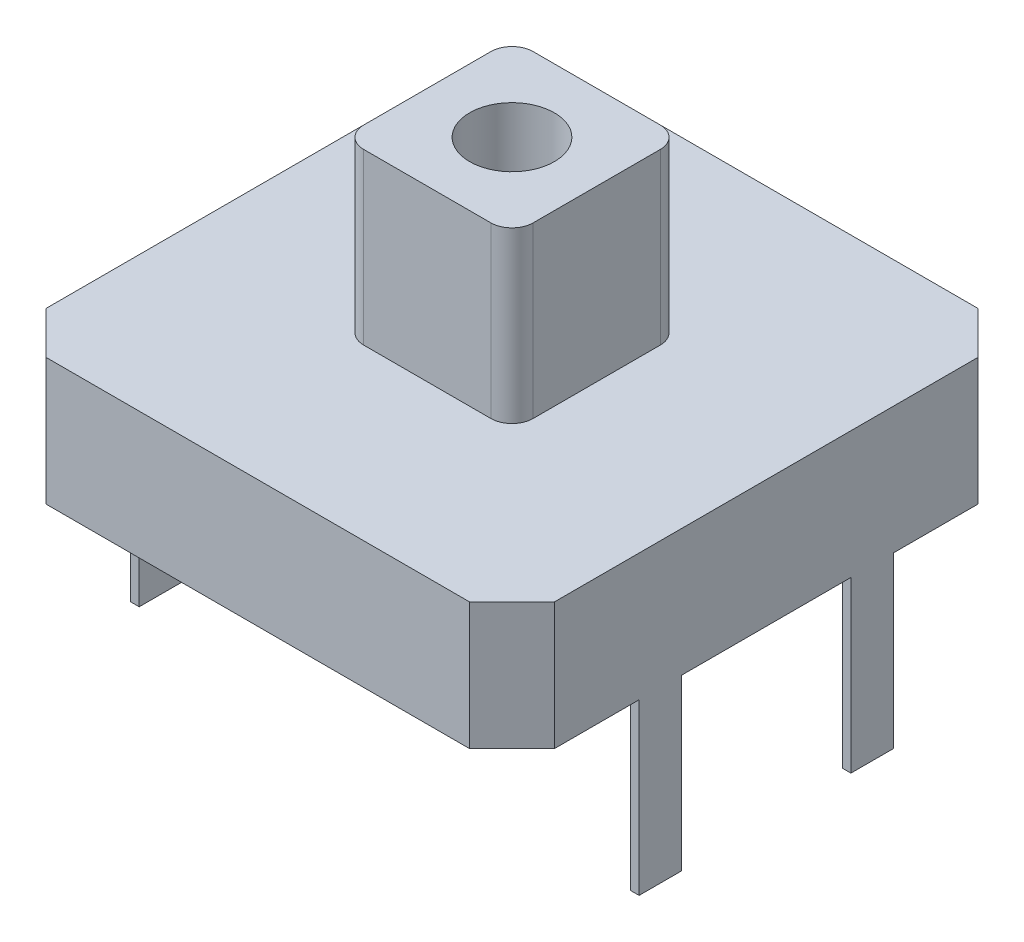
from build123d import *

# Parameters (mm, degrees)
SKETCH1_W           = 12
SKETCH1_H           = 12
BOSS_EXTRUDE1_DEPTH = 3
SKETCH2_W           = 4
SKETCH2_H           = 4
BOSS_EXTRUDE2_DEPTH = 4
SKETCH3_R           = 1
CUT_EXTRUDE1_DEPTH  = 3
FILLET2_R           = 0.5
SKETCH4_W           = 0.2
SKETCH4_H           = 1
BOSS_EXTRUDE3_DEPTH = 4
CHAMFER1_SIZE       = 1


with BuildPart() as part:
    # Sketch1 → Boss-Extrude1 (new body)
    with BuildSketch(Plane(origin=(0, 0, 0), x_dir=(1, 0, 0), z_dir=(0, 1, 0))):
        Rectangle(SKETCH1_W, SKETCH1_H)
    extrude(amount=BOSS_EXTRUDE1_DEPTH)

    # Sketch2 → Boss-Extrude2 (add)
    with BuildSketch(Plane(origin=(0, 3, 0), x_dir=(1, 0, 0), z_dir=(0, 1, 0))):
        Rectangle(SKETCH2_W, SKETCH2_H)
    extrude(amount=BOSS_EXTRUDE2_DEPTH)

    # Sketch3 → Cut-Extrude1 (cut)
    with BuildSketch(Plane(origin=(0, 7, 0), x_dir=(1, 0, 0), z_dir=(0, 1, 0))):
        Circle(SKETCH3_R)
    extrude(amount=-CUT_EXTRUDE1_DEPTH, mode=Mode.SUBTRACT)

    # Fillet2
    fillet2_edges = [part.edges().sort_by_distance(p)[0] for p in [
        (2, 5, 2),
        (2, 5, -2),
        (-2, 5, -2),
        (-2, 5, 2),
    ]]
    fillet(fillet2_edges, radius=FILLET2_R)

    # Sketch4 → Boss-Extrude3 (add)
    with BuildSketch(Plane.XZ):
        with Locations((-5.9, -2.5)):
            Rectangle(SKETCH4_W, SKETCH4_H)
        with Locations((-5.9, 2.5)):
            Rectangle(SKETCH4_W, SKETCH4_H)
        with Locations((5.9, 2.5)):
            Rectangle(SKETCH4_W, SKETCH4_H)
        with Locations((5.9, -2.5)):
            Rectangle(SKETCH4_W, SKETCH4_H)
    extrude(amount=BOSS_EXTRUDE3_DEPTH)

    # Chamfer1
    chamfer1_edges = [part.edges().sort_by_distance(p)[0] for p in [
        (6, 1.5, 6),
        (-6, 1.5, 6),
        (-6, 1.5, -6),
        (6, 1.5, -6),
    ]]
    chamfer(chamfer1_edges, length=CHAMFER1_SIZE)


solid = part.part
